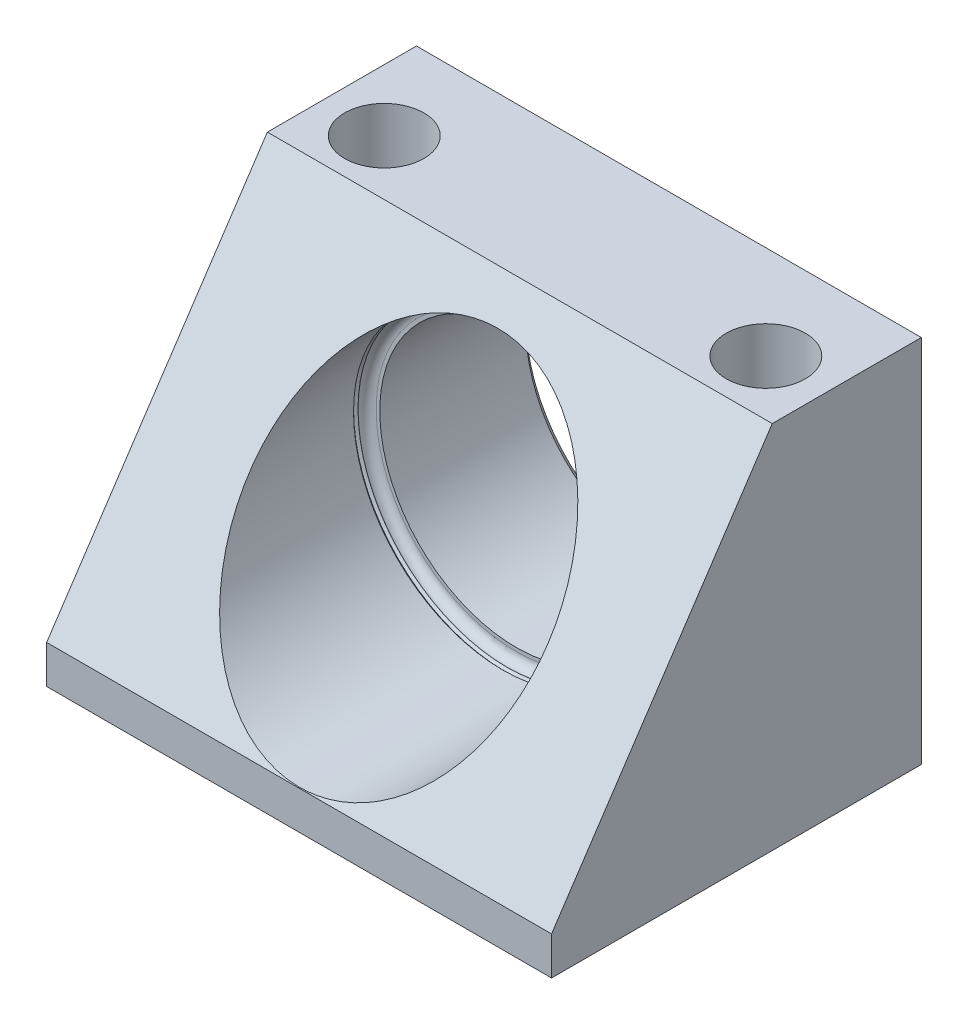
from build123d import *

# Parameters (mm, degrees)
SKETCH1_W          = 86.0044
SKETCH1_H          = 62.992
SKETCH1_R          = 23.2665
EXTRUDE1_DEPTH     = 62.992
CUT_EXTRUDE1_DEPTH = 87.0044
SKETCH3_R          = 25.4
CUT_EXTRUDE2_DEPTH = 37.0078
FILLET1_R          = 1.524
HOLE1_D            = 13.4874
HOLE1_DEPTH        = 62.992


with BuildPart() as part:
    # Sketch1 → Extrude1 (new body)
    with BuildSketch(Plane.XY):
        with Locations((0, -0.508)):
            Rectangle(SKETCH1_W, SKETCH1_H)
        Circle(SKETCH1_R, mode=Mode.SUBTRACT)
    extrude(amount=-EXTRUDE1_DEPTH)

    # Sketch2 → Cut-Extrude1 (cut, through all)
    with BuildSketch(Plane(origin=(43.0022, 0, 0), x_dir=(0, 0, -1), z_dir=(1, 0, 0))):
        Polygon((0, 30.988), (37.592, 30.988), (0, -25.5016), align=None)
    extrude(amount=-CUT_EXTRUDE1_DEPTH, mode=Mode.SUBTRACT)

    # Sketch3 → Cut-Extrude2 (cut)
    with BuildSketch(Plane(origin=(0, 0, 0), x_dir=(-1, 0, 0), z_dir=(0, 0, -1))):
        with Locations(Location((0, 0, 0), (0, 0, 180))):  # turned: the seam where the file's is
            Circle(SKETCH3_R)
    extrude(amount=CUT_EXTRUDE2_DEPTH, mode=Mode.SUBTRACT)

    # Fillet1
    fillet1_edges = [part.edges().sort_by_distance(p)[0] for p in [
        (-25.4, 0, -37.0078),
    ]]
    fillet(fillet1_edges, radius=FILLET1_R)

    # Hole1
    with Locations(Plane(origin=(0, 30.988, 0), x_dir=(-1, 0, 0), z_dir=(0, 1, 0))):
        with Locations((32.512, -47.0154), (-32.4866, -47.0154)):
            Hole(HOLE1_D / 2, depth=HOLE1_DEPTH)

    # Sketch6 → Cut-Revolve1 (revolve, cut)
    with BuildSketch(Plane(origin=(0, 0, 0), x_dir=(-1, 0, 0), z_dir=(0, 1, 0)), mode=Mode.PRIVATE) as cut_revolve1_sk:
        Polygon((25.4, -34.671), (25.4, -35.433), (25.781, -35.052), align=None)
        Polygon((23.2665, -61.8745), (23.2665, -62.992), (24.384, -62.992), align=None)
    revolve(cut_revolve1_sk.sketch.rotate(Axis((0, 0, 17.508123997), (0, 0, -1)), 180), axis=Axis((0, 0, 17.508123997), (0, 0, -1)), mode=Mode.SUBTRACT)  # turned: the seam where the file's is


solid = part.part
